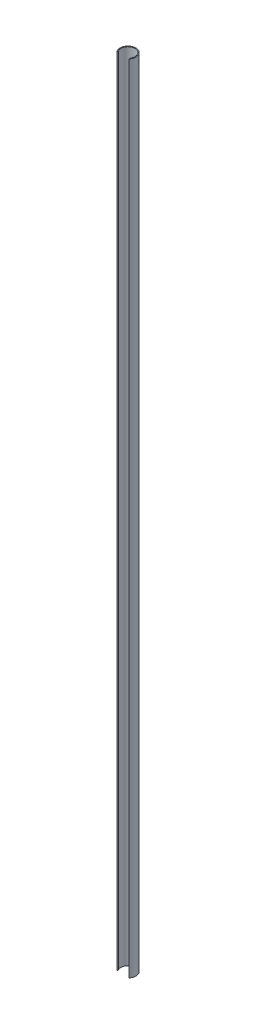
from build123d import *

# Parameters (mm, degrees)
SKETCH1_R           = 0.9017
SKETCH1_R_2         = 0.8001
BOSS_EXTRUDE1_DEPTH = 90
SKETCH2_W           = 1.4
SKETCH2_H           = 0.622776606
CUT_EXTRUDE1_DEPTH  = 90


with BuildPart() as part:
    # Sketch1 → Boss-Extrude1 (new body)
    with BuildSketch(Plane(origin=(0, 0, 0), x_dir=(1, 0, 0), z_dir=(0, 1, 0))):
        Circle(SKETCH1_R)
        Circle(SKETCH1_R_2, mode=Mode.SUBTRACT)
    extrude(amount=BOSS_EXTRUDE1_DEPTH)

    # Sketch2 → Cut-Extrude1 (cut)
    with BuildSketch(Plane(origin=(0, 90, 0), x_dir=(1, 0, 0), z_dir=(0, 1, 0))):
        with Locations((0, -0.590311697)):
            Rectangle(SKETCH2_W, SKETCH2_H)
    extrude(amount=-CUT_EXTRUDE1_DEPTH, mode=Mode.SUBTRACT)


solid = part.part
